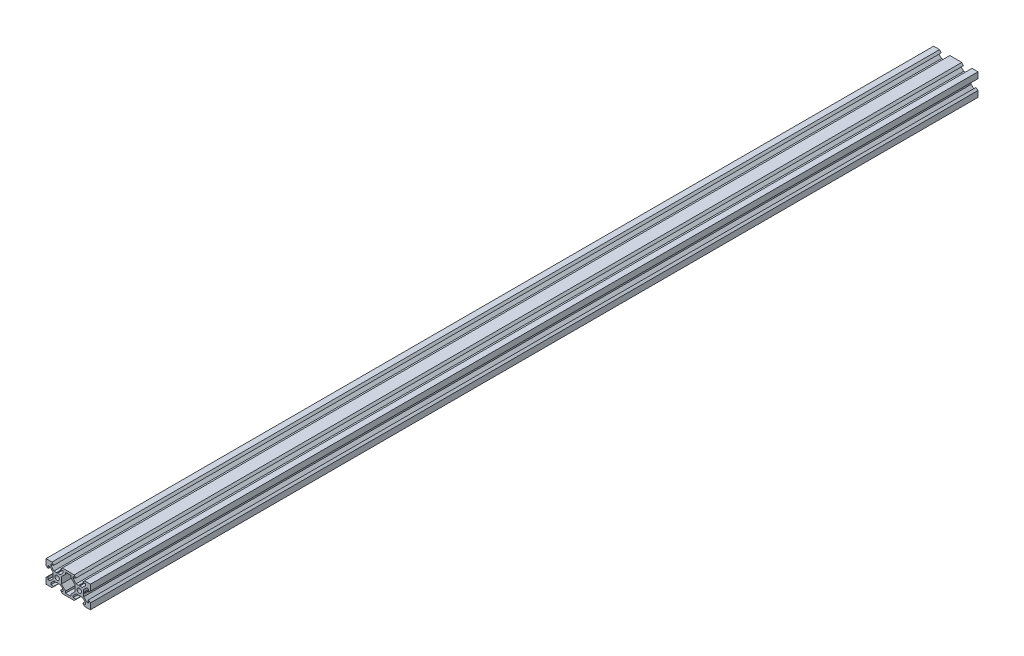
from build123d import *

# Parameters (mm, degrees)
SKETCH1_R           = 2
BOSS_EXTRUDE1_DEPTH = 1000
SKETCH2_W           = 40
SKETCH2_H           = 20
CUT_EXTRUDE1_DEPTH  = 200


with BuildPart() as part:
    # Sketch1 → Boss-Extrude1 (new body)
    with BuildSketch(Plane.XY):
        Polygon((-5.389620664, 10), (5.389620664, 10), (6.9, 8.2), (4.5, 8.2), (4.5, 6.556171609), (7.151917065, 3.899773171), (9.480384758, 3.899773171), (10, 3.599773171), (10.519615242, 3.899773171), (12.848082935, 3.899773171), (15.5, 6.556171609), (15.5, 8.2), (13.1, 8.2), (14.610379336, 10), (20, 10), (20, 4.610379336), (18.2, 3.1), (18.2, 5.5), (16.556171609, 5.5), (13.9, 2.839339828), (13.9, 0.519615231), (13.599999981, 0), (13.9, -0.519615231), (13.9, -2.839339828), (16.556171609, -5.5), (18.2, -5.5), (18.2, -3.1), (20, -4.610379336), (20, -10), (14.610379336, -10), (13.1, -8.2), (15.5, -8.2), (15.5, -6.556171609), (12.839339828, -3.9), (10.519222362, -3.9), (10, -3.600226829), (9.480777638, -3.9), (7.160660172, -3.9), (4.5, -6.556171609), (4.5, -8.2), (6.9, -8.2), (5.389620664, -10), (-5.389620664, -10), (-6.9, -8.2), (-4.5, -8.2), (-4.5, -6.556171609), (-7.160432959, -3.900226829), (-9.480384758, -3.900226829), (-10, -3.600226829), (-10.519615242, -3.900226829), (-12.839339828, -3.9), (-15.5, -6.556171609), (-15.5, -8.2), (-13.1, -8.2), (-14.610379336, -10), (-20, -10), (-20, -4.610379336), (-18.2, -3.1), (-18.2, -5.5), (-16.556171609, -5.5), (-13.9, -2.839339828), (-13.9, -0.519615231), (-13.599999981, 0), (-13.9, 0.519615231), (-13.9, 2.839339828), (-16.556171609, 5.5), (-18.2, 5.5), (-18.2, 3.1), (-20, 4.610379336), (-20, 10), (-14.610379336, 10), (-13.1, 8.2), (-15.5, 8.2), (-15.5, 6.556171609), (-12.839339828, 3.9), (-10.519615242, 3.899773171), (-10, 3.599773171), (-9.480384758, 3.899773171), (-7.160660172, 3.9), (-4.5, 6.556171609), (-4.5, 8.2), (-6.9, 8.2), align=None)
        with Locations((-10, 0)):
            Circle(SKETCH1_R, mode=Mode.SUBTRACT)
        with Locations((10, 0)):
            Circle(SKETCH1_R, mode=Mode.SUBTRACT)
        Polygon((-6.1, -2.839339828), (-2.376887287, -6.556171609), (-2.376887287, -8.2), (2.376887287, -8.2), (2.376887287, -6.556171609), (6.1, -2.839339828), (6.1, 2.839339828), (2.383168219, 6.556171609), (2.383168219, 8.2), (-2.383168219, 8.2), (-2.383168219, 6.556171609), (-6.1, 2.839339828), align=None, mode=Mode.SUBTRACT)
    extrude(amount=BOSS_EXTRUDE1_DEPTH)

    # Sketch2 → Cut-Extrude1 (cut)
    with BuildSketch(Plane.XY.offset(1000)):
        Rectangle(SKETCH2_W, SKETCH2_H)
    extrude(amount=-CUT_EXTRUDE1_DEPTH, mode=Mode.SUBTRACT)


solid = part.part
